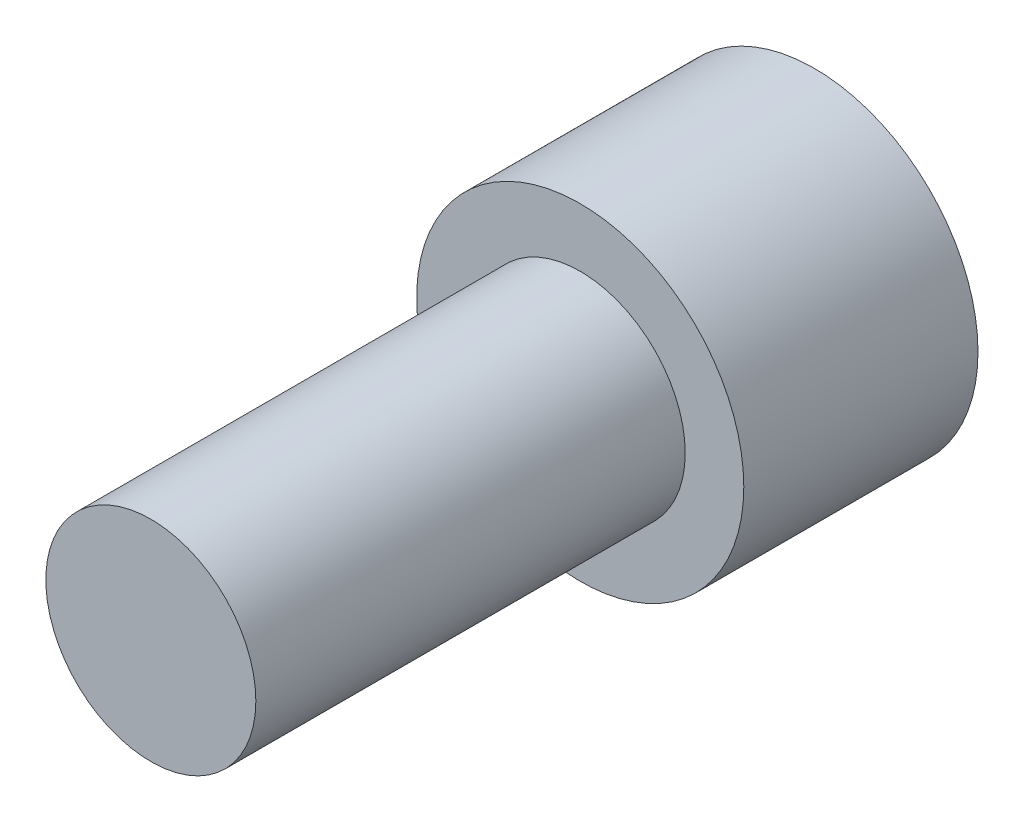
from build123d import *

# Parameters (mm, degrees)
SKETCH2_R           = 4.191
BOSS_EXTRUDE1_DEPTH = 6
SKETCH4_R           = 2.69
BOSS_EXTRUDE2_DEPTH = 11


with BuildPart() as part:
    # Sketch2 → Boss-Extrude1 (new body)
    with BuildSketch(Plane.XY):
        Circle(SKETCH2_R)
    extrude(amount=BOSS_EXTRUDE1_DEPTH)

    # Sketch4 → Boss-Extrude2 (add)
    with BuildSketch(Plane.XY.offset(6)):
        Circle(SKETCH4_R)
    extrude(amount=BOSS_EXTRUDE2_DEPTH)


solid = part.part
